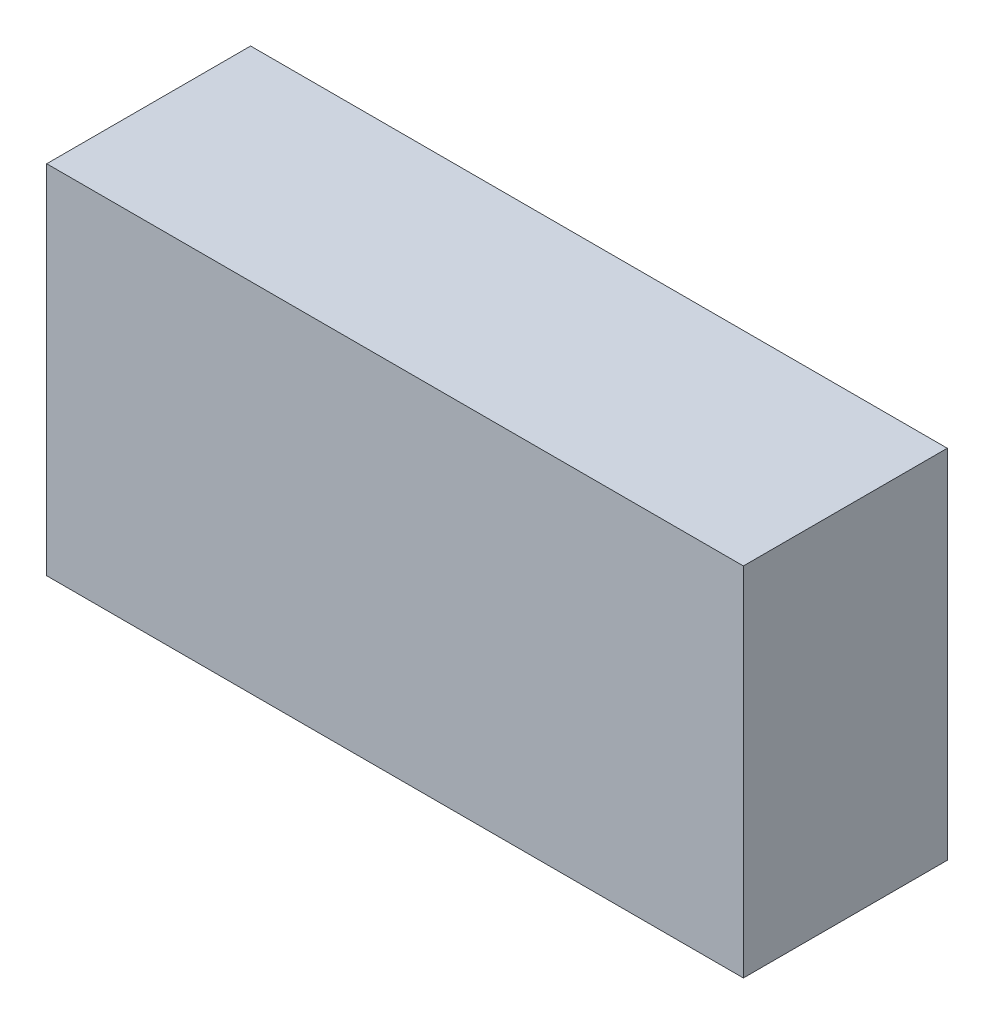
from build123d import *

# Parameters (mm, degrees)
SKETCH2_W           = 41
SKETCH2_H           = 21
BOSS_EXTRUDE1_DEPTH = 12


with BuildPart() as part:
    # Sketch2 → Boss-Extrude1 (new body)
    with BuildSketch(Plane.XY):
        with Locations((20.5, 10.5)):
            Rectangle(SKETCH2_W, SKETCH2_H)
    extrude(amount=BOSS_EXTRUDE1_DEPTH)


solid = part.part
